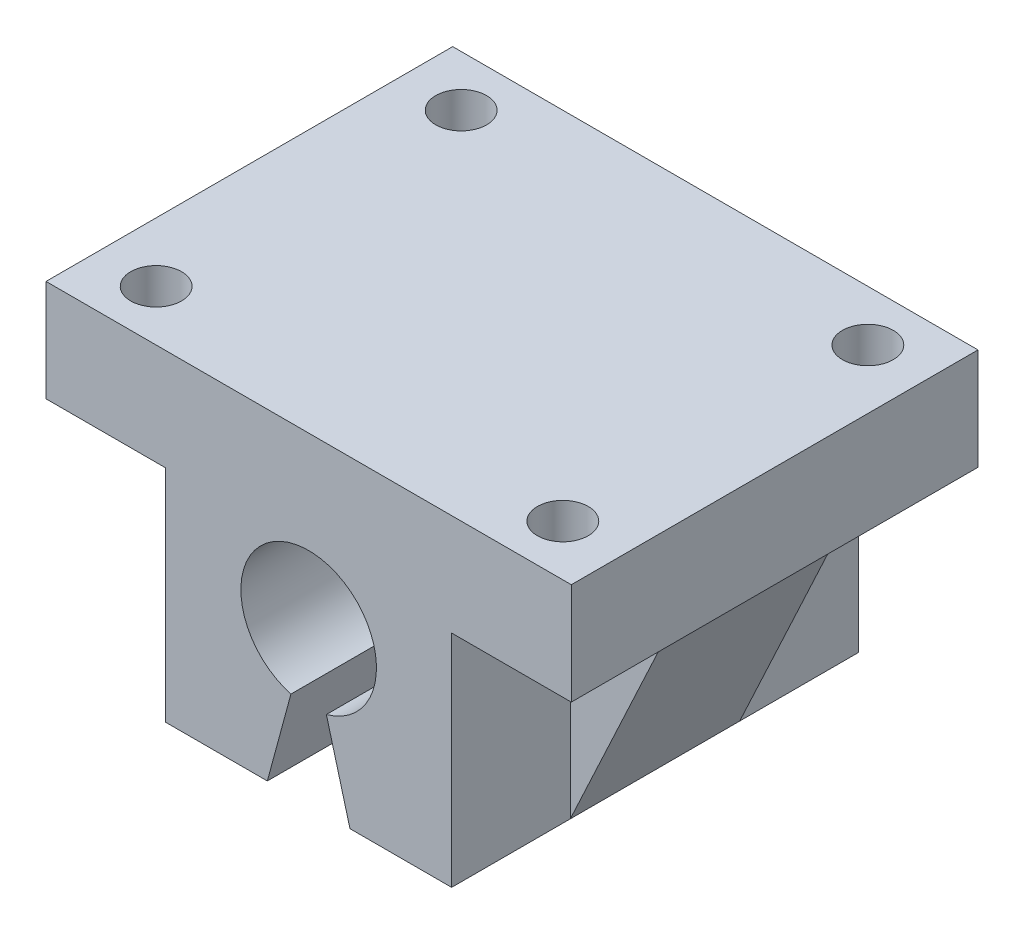
from build123d import *

# Parameters (mm, degrees)
SALIENTE_EXTRUIR2_DEPTH = 12
SALIENTE_EXTRUIR3_DEPTH = 5
CORTAR_EXTRUIR1_REACH   = 21
CROQUIS4_R              = 1.5


with BuildPart() as part:
    # Croquis2 → Saliente-Extruir2 (new body, symmetric)
    with BuildSketch(Plane.XY):
        with BuildLine():
            Line((8.438000444, -19), (8.438000444, -6))
            Line((8.438000444, -6), (14.5, -6))
            Line((14.5, -6), (15.5, -6))
            Line((15.5, -6), (15.5, 0))
            Line((15.5, 0), (-15.5, 0))
            Line((-15.5, 0), (-15.5, -6))
            Line((-15.5, -6), (-14.5, -6))
            Line((-14.5, -6), (-8.438000444, -6))
            Line((-8.438000444, -6), (-8.438000444, -19))
            Line((-8.438000444, -19), (-2.438000444, -19))
            Line((-2.438000444, -19), (-1.045861913, -13.860851313))
            ThreePointArc((-1.045861913, -13.860851313), (-2.430694587, -6.823252634), (4, -10))
            ThreePointArc((4, -10), (3.176747366, -12.430694587), (1.045861913, -13.860851313))
            Line((1.045861913, -13.860851313), (2.438000444, -19))
            Line((2.438000444, -19), (8.438000444, -19))
        make_face()
    extrude(amount=SALIENTE_EXTRUIR2_DEPTH, both=True)

    # Croquis3 → Saliente-Extruir3 (add, symmetric)
    with BuildSketch(Plane.XY):
        Polygon((8.438000444, -6), (14.5, -6), (8.438000444, -19), align=None)
        Polygon((-8.438000444, -6), (-8.438000444, -19), (-14.5, -6), align=None)
    extrude(amount=SALIENTE_EXTRUIR3_DEPTH, both=True)

    # Croquis4 → Cortar-Extruir1 (cut, up to next)
    with BuildSketch(Plane(origin=(0, 0, 0), x_dir=(1, 0, 0), z_dir=(0, 1, 0)), mode=Mode.PRIVATE) as cortar_extruir1_sk1:
        with Locations((-12, 9)):
            Circle(CROQUIS4_R)
    cortar_extruir1_tool1 = extrude(cortar_extruir1_sk1.sketch, amount=-CORTAR_EXTRUIR1_REACH, mode=Mode.PRIVATE) & part.part
    add(cortar_extruir1_tool1.solids().sort_by_distance((-12, 0, -9))[0], mode=Mode.SUBTRACT)
    # Croquis4 → Cortar-Extruir1 (cut, up to next)
    with BuildSketch(Plane(origin=(0, 0, 0), x_dir=(1, 0, 0), z_dir=(0, 1, 0)), mode=Mode.PRIVATE) as cortar_extruir1_sk2:
        with Locations((12, 9)):
            Circle(CROQUIS4_R)
    cortar_extruir1_tool2 = extrude(cortar_extruir1_sk2.sketch, amount=-CORTAR_EXTRUIR1_REACH, mode=Mode.PRIVATE) & part.part
    add(cortar_extruir1_tool2.solids().sort_by_distance((12, 0, -9))[0], mode=Mode.SUBTRACT)
    # Croquis4 → Cortar-Extruir1 (cut, up to next)
    with BuildSketch(Plane(origin=(0, 0, 0), x_dir=(1, 0, 0), z_dir=(0, 1, 0)), mode=Mode.PRIVATE) as cortar_extruir1_sk3:
        with Locations((12, -9)):
            Circle(CROQUIS4_R)
    cortar_extruir1_tool3 = extrude(cortar_extruir1_sk3.sketch, amount=-CORTAR_EXTRUIR1_REACH, mode=Mode.PRIVATE) & part.part
    add(cortar_extruir1_tool3.solids().sort_by_distance((12, 0, 9))[0], mode=Mode.SUBTRACT)
    # Croquis4 → Cortar-Extruir1 (cut, up to next)
    with BuildSketch(Plane(origin=(0, 0, 0), x_dir=(1, 0, 0), z_dir=(0, 1, 0)), mode=Mode.PRIVATE) as cortar_extruir1_sk4:
        with Locations((-12, -9)):
            Circle(CROQUIS4_R)
    cortar_extruir1_tool4 = extrude(cortar_extruir1_sk4.sketch, amount=-CORTAR_EXTRUIR1_REACH, mode=Mode.PRIVATE) & part.part
    add(cortar_extruir1_tool4.solids().sort_by_distance((-12, 0, 9))[0], mode=Mode.SUBTRACT)


solid = part.part
